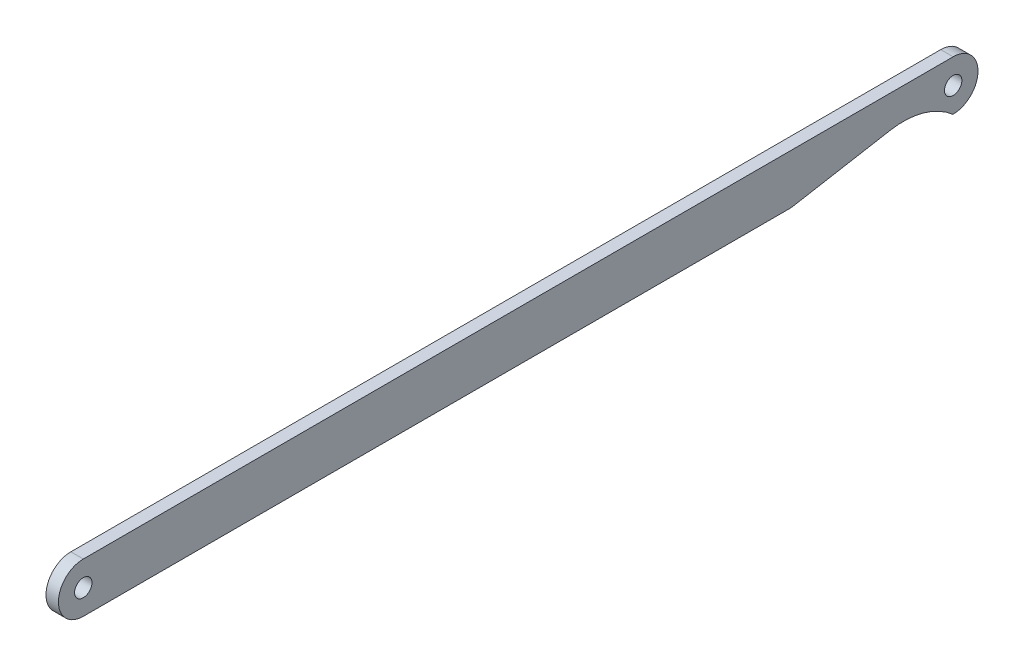
from build123d import *

# Parameters (mm, degrees)
SKETCH_1_R          = 0.7
EXTRUDE_1_DEPTH     = 1
CUT_EXTRUDE_1_DEPTH = 2


with BuildPart() as part:
    # Эскиз1 → Вытянуть1 (new body)
    with BuildSketch(Plane(origin=(0, 0, 0), x_dir=(0, 0, -1), z_dir=(1, 0, 0))):
        with BuildLine():
            Line((0, 0), (70, 0))
            ThreePointArc((70, 0), (72, -2), (70, -4))
            Line((70, -4), (0, -4))
            ThreePointArc((0, -4), (-2, -2), (0, 0))
        make_face()
        with Locations((0, -2)):
            Circle(SKETCH_1_R, mode=Mode.SUBTRACT)
        with Locations((70, -2)):
            Circle(SKETCH_1_R, mode=Mode.SUBTRACT)
    extrude(amount=EXTRUDE_1_DEPTH)

    # Эскиз2 → Вырез-Вытянуть1 (cut, through all)
    with BuildSketch(Plane(origin=(1, 0, 0), x_dir=(0, 0, -1), z_dir=(1, 0, 0))):
        with BuildLine():
            Line((185.588178167, -105.966859724), (69.968626967, -4))
            ThreePointArc((69.968626967, -4), (67.624087686, -2.723985874), (64.958110934, -2.591153482))
            Line((64.958110934, -2.591153482), (56.968145289, -4))
            Line((56.968145289, -4), (-94.849228607, -30.769499158))
            Line((-94.849228607, -30.769499158), (-174.701887648, -328.568151357))
            Line((-174.701887648, -328.568151357), (105.735519126, -403.765511923))
            Line((105.735519126, -403.765511923), (185.588178167, -105.966859724))
        make_face()
    extrude(amount=-CUT_EXTRUDE_1_DEPTH, mode=Mode.SUBTRACT)


solid = part.part
